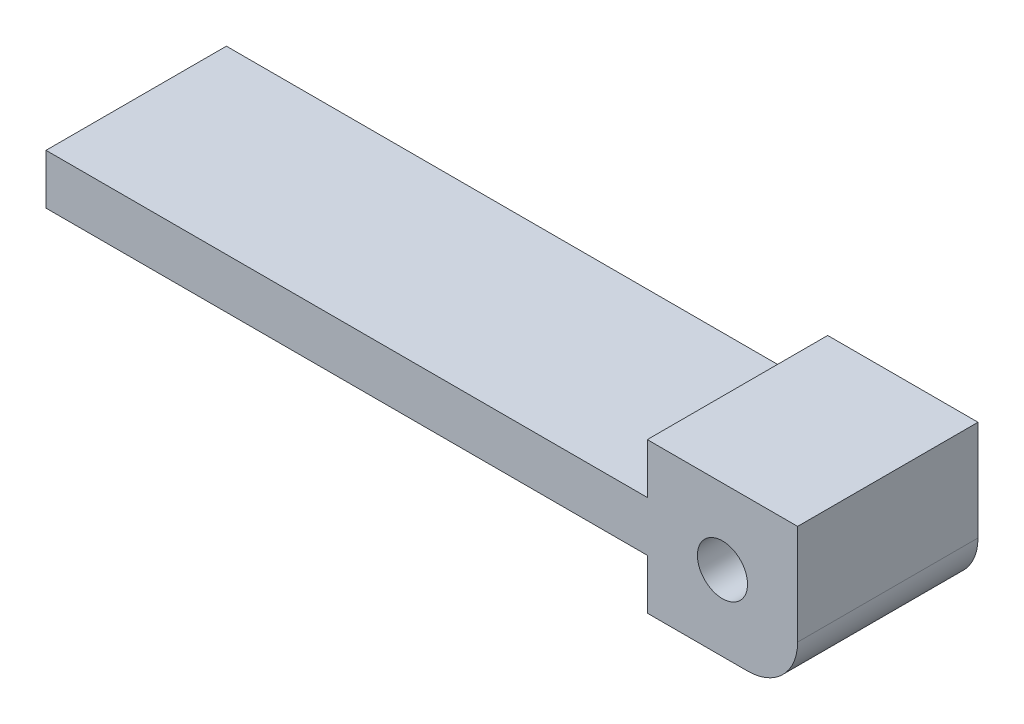
from build123d import *

# Parameters (mm, degrees)
AUFSATZ_LINEAR_AUSTRAGEN1_DEPTH = 18
SKIZZE2_R                       = 2.5
SCHNITT_LINEAR_AUSTRAGEN1_DEPTH = 19
VERRUNDUNG1_R                   = 5


with BuildPart() as part:
    # Skizze1 → Aufsatz-Linear austragen1 (new body)
    with BuildSketch(Plane.XY):
        Polygon((0, 0), (-15, 0), (-15, 5), (-75, 5), (-75, 10), (-15, 10), (-15, 15), (0, 15), align=None)
    extrude(amount=AUFSATZ_LINEAR_AUSTRAGEN1_DEPTH)

    # Skizze2 → Schnitt-Linear austragen1 (cut, through all)
    with BuildSketch(Plane.XY.offset(18)):
        with Locations((-7.5, 7.5)):
            Circle(SKIZZE2_R)
    extrude(amount=-SCHNITT_LINEAR_AUSTRAGEN1_DEPTH, mode=Mode.SUBTRACT)

    # Verrundung1
    verrundung1_edges = [part.edges().sort_by_distance(p)[0] for p in [
        (0, 0, 9),
    ]]
    fillet(verrundung1_edges, radius=VERRUNDUNG1_R)


solid = part.part
